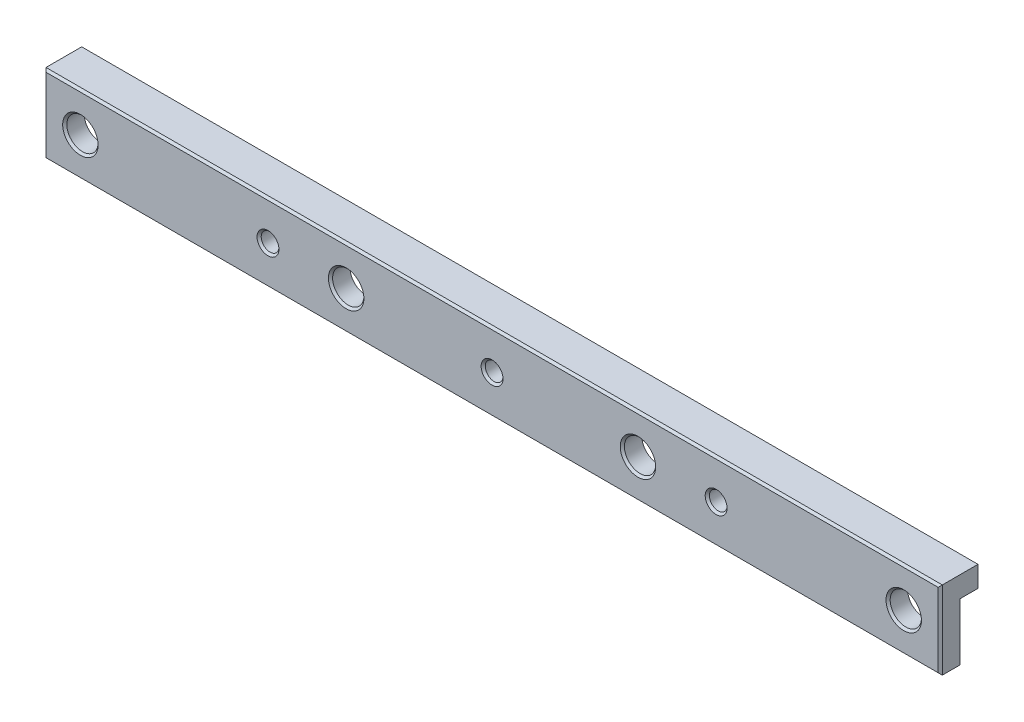
from build123d import *

# Parameters (mm, degrees)
SKETCH1_W               = 172
SKETCH1_H               = 15
BOSS_EXTRUDE1_DEPTH     = 7.25
CUT_EXTRUDE1_START      = -7.25
SKETCH1_6_W             = 172
SKETCH1_6_H             = 11
CUT_EXTRUDE1_DEPTH      = 3.5
SKETCH2_R               = 1.7
SKETCH2_R_2             = 3
CUT_EXTRUDE2_DEPTH      = 1
CUT_EXTRUDE2_DEPTH_BACK = 8.25
CHAMFER1_SIZE           = 0.4


with BuildPart() as part:
    # Sketch1 → Boss-Extrude1 (new body)
    with BuildSketch(Plane.XY):
        Rectangle(SKETCH1_W, SKETCH1_H)
    extrude(amount=-BOSS_EXTRUDE1_DEPTH)

    # Sketch1_6 → Cut-Extrude1 (cut)
    with BuildSketch(Plane.XY.offset(CUT_EXTRUDE1_START)):
        with Locations((0, -2)):
            Rectangle(SKETCH1_6_W, SKETCH1_6_H)
    extrude(amount=CUT_EXTRUDE1_DEPTH, mode=Mode.SUBTRACT)

    # Sketch2 → Cut-Extrude2 (cut, two sides)
    with BuildSketch(Plane.XY) as cut_extrude2_sk:
        with Locations((-43, 0)):
            Circle(SKETCH2_R)
        Circle(SKETCH2_R)
        with Locations((43, 0)):
            Circle(SKETCH2_R)
        with Locations((-79, 0)):
            Circle(SKETCH2_R_2)
        with Locations((79, 0)):
            Circle(SKETCH2_R_2)
        with Locations((-28, 0)):
            Circle(SKETCH2_R_2)
        with Locations((28, 0)):
            Circle(SKETCH2_R_2)
    extrude(amount=CUT_EXTRUDE2_DEPTH, mode=Mode.SUBTRACT)
    extrude(cut_extrude2_sk.sketch, amount=-CUT_EXTRUDE2_DEPTH_BACK, mode=Mode.SUBTRACT)

    # Chamfer1
    chamfer1_edges = [part.edges().sort_by_distance(p)[0] for p in [
        (76, 0, 0),
        (-82, 0, 0),
        (41.3, 0, 0),
        (-44.7, 0, 0),
        (-31, 0, 0),
        (25, 0, 0),
        (-1.7, 0, 0),
        (0, -7.5, 0),
        (-86, 0, 0),
        (0, 7.5, 0),
        (86, 0, 0),
    ]]
    chamfer(chamfer1_edges, length=CHAMFER1_SIZE)


solid = part.part
